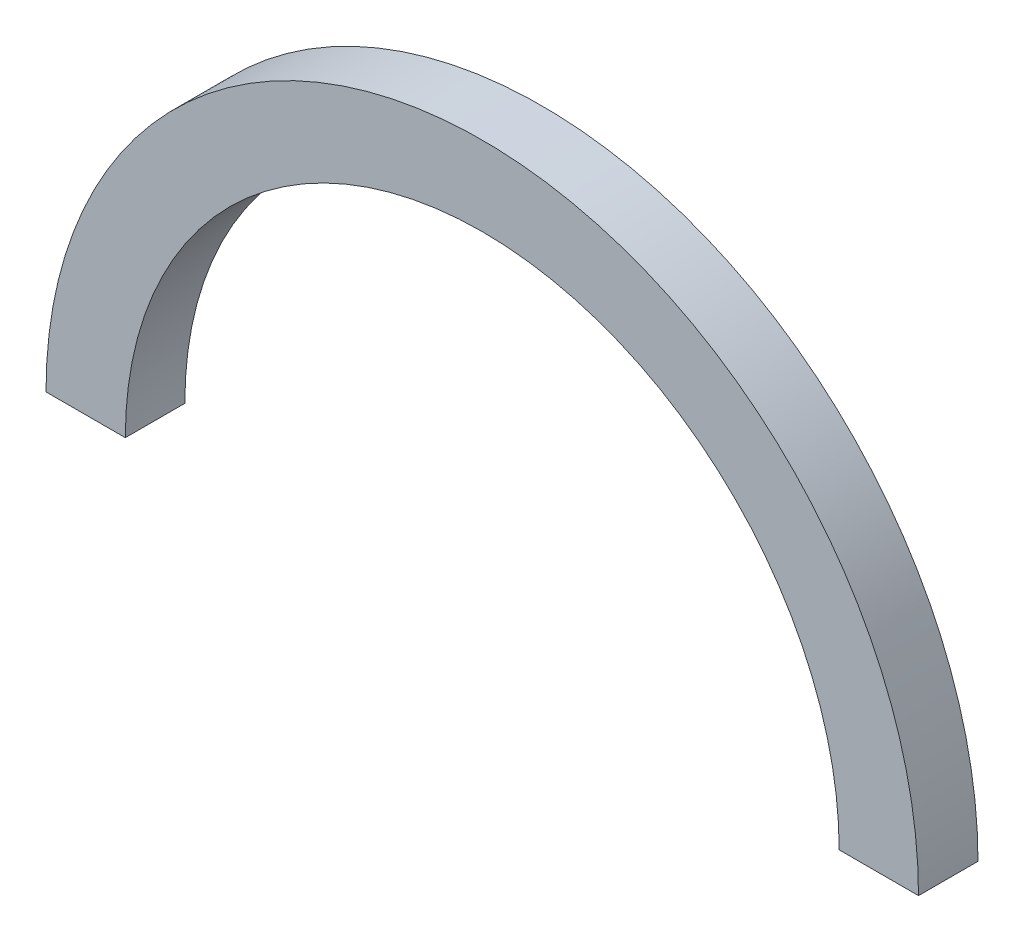
from build123d import *

# Parameters (mm, degrees)
ESQUISSE3_W = 200
ESQUISSE3_H = 150


with BuildPart() as part:
    # Balayage3: sweep along a path in Esquisse5
    with BuildLine(Plane.XY.offset(-6700.621745368)) as balayage3_path:
        ThreePointArc((2495.771951508, 0), (3495.771951508, 1000), (4495.771951508, 0))
    # Esquisse3 → Balayage3 (sweep)
    with BuildSketch(Plane(origin=(0, 0, 0), x_dir=(1, 0, 0), z_dir=(0, 1, 0))):
        with Locations((2495.771951508, 6700.621745368)):
            Rectangle(ESQUISSE3_W, ESQUISSE3_H)
    sweep(path=balayage3_path.line)


solid = part.part
